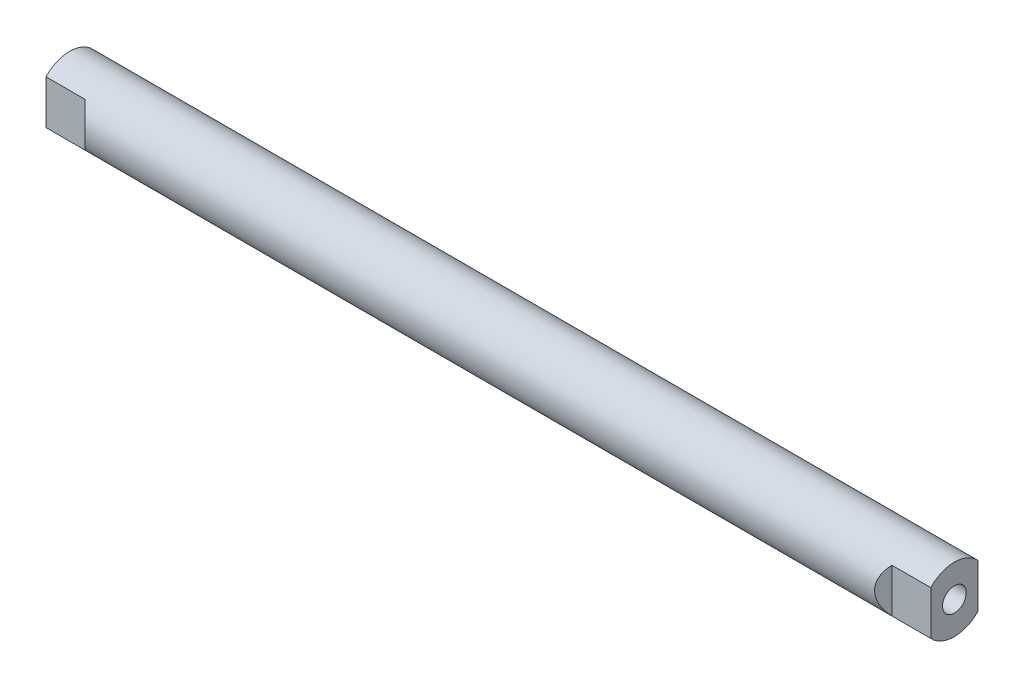
from build123d import *

# Parameters (mm, degrees)
SKETCH4_W               = 296
SKETCH4_H               = 10.8
CUT_EXTRUDE1_DEPTH      = 11.8
CUT_EXTRUDE1_DEPTH_BACK = 11.8
SKETCH2_R               = 3.97
EXTRUDE2_DEPTH          = 30.6
SKETCH3_R               = 3.97
EXTRUDE3_DEPTH          = 30.6


with BuildPart() as part:
    # Sketch4 → Revolve1 (revolve)
    with BuildSketch(Plane.XY):
        with Locations((0, 5.4)):
            Rectangle(SKETCH4_W, SKETCH4_H)
    revolve(axis=Axis((-180.472392976, 0, 0), (1, 0, 0)))

    # Sketch5 → Cut-Extrude1 (cut, two sides)
    with BuildSketch(Plane(origin=(0, 0, 0), x_dir=(1, 0, 0), z_dir=(0, 1, 0))) as cut_extrude1_sk:
        Polygon((-172.80595371, 7.9), (-135, 7.9), (-126.264796731, 16.635203269), (-172.80595371, 16.635203269), align=None)
        Polygon((-172.80595371, -7.9), (-135, -7.9), (-126.264796731, -16.635203269), (-172.80595371, -16.635203269), align=None)
        Polygon((135, -7.9), (126.264796731, -16.635203269), (172.80595371, -16.635203269), (172.80595371, -7.9), align=None)
        Polygon((135, 7.9), (126.264796731, 16.635203269), (172.80595371, 16.635203269), (172.80595371, 7.9), align=None)
    extrude(amount=CUT_EXTRUDE1_DEPTH, mode=Mode.SUBTRACT)
    extrude(cut_extrude1_sk.sketch, amount=-CUT_EXTRUDE1_DEPTH_BACK, mode=Mode.SUBTRACT)

    # Sketch2 → Extrude2 (cut)
    with BuildSketch(Plane(origin=(-148, 0, 0), x_dir=(0, 0, -1), z_dir=(1, 0, 0))):
        Circle(SKETCH2_R)
    extrude(amount=EXTRUDE2_DEPTH, mode=Mode.SUBTRACT)

    # Sketch3 → Extrude3 (cut)
    with BuildSketch(Plane.ZY.offset(-148)):
        Circle(SKETCH3_R)
    extrude(amount=EXTRUDE3_DEPTH, mode=Mode.SUBTRACT)


solid = part.part
